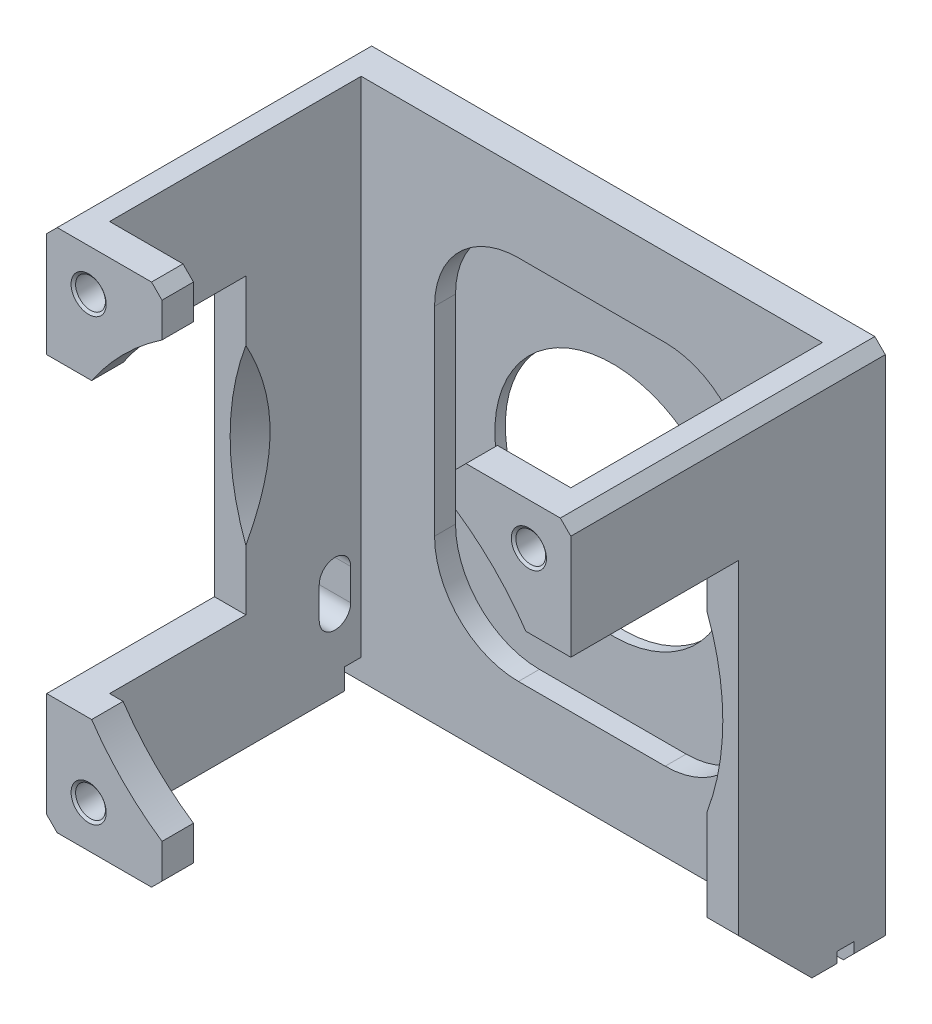
from build123d import *

# Parameters (mm, degrees)
SKETCH_1_W                   = 50
SKETCH_1_H                   = 30
SKETCH_1_W_2                 = 44
SKETCH_1_H_2                 = 24
EXTRUDE_1_DEPTH              = 50
CUT_EXTRUDE_START            = -14
CUT_EXTRUDE_1_DEPTH          = 17
SKETCH_3_R                   = 11.25
CUT_EXTRUDE_2_DEPTH          = 4
HOLE_WIZARD_4_40_D           = 2.8448
HOLE_WIZARD_4_40_DEPTH       = 3
HOLE_WIZARD_4_40_CSINK_D     = 3.3528
HOLE_WIZARD_4_40_CSINK_ANGLE = 110
SKETCH_10_W                  = 1.6
SKETCH_10_H                  = 2
CUT_EXTRUDE_4_DEPTH          = 51
CUT_EXTRUDE_3_DEPTH          = 2
CHAMFER_1_SIZE               = 8
CHAMFER_2_SIZE               = 1
CUT_EXTRUDE_5_REACH          = 52


with BuildPart() as part:
    # Эскиз1 → Бобышка-Вытянуть1 (new body)
    with BuildSketch(Plane(origin=(0, 0, 0), x_dir=(1, 0, 0), z_dir=(0, 1, 0))):
        Rectangle(SKETCH_1_W, SKETCH_1_H)
        Rectangle(SKETCH_1_W_2, SKETCH_1_H_2, mode=Mode.SUBTRACT)
    extrude(amount=EXTRUDE_1_DEPTH)

    # Эскиз2 → Вырез-Вытянуть1 (cut, through all)
    with BuildSketch(Plane(origin=(0, 0, -15), x_dir=(-1, 0, 0), z_dir=(0, 0, -1)).offset(CUT_EXTRUDE_START)):
        with BuildLine():
            ThreePointArc((-14, 45.712315177), (-17.67766953, 42.67766953), (-20.712315177, 39))
            Line((-20.712315177, 39), (-25, 39))
            Line((-25, 39), (-25, 11))
            Line((-25, 11), (-20.712315177, 11))
            ThreePointArc((-20.712315177, 11), (-17.67766953, 7.32233047), (-14, 4.287684823))
            Line((-14, 4.287684823), (-14, 0))
            Line((-14, 0), (14, 0))
            Line((14, 0), (14, 4.287684823))
            ThreePointArc((14, 4.287684823), (17.67766953, 7.32233047), (20.712315177, 11))
            Line((20.712315177, 11), (25, 11))
            Line((25, 11), (25, 39))
            Line((25, 39), (20.712315177, 39))
            ThreePointArc((20.712315177, 39), (17.67766953, 42.67766953), (14, 45.712315177))
            Line((14, 45.712315177), (14, 50))
            Line((14, 50), (-14, 50))
            Line((-14, 50), (-14, 45.712315177))
        make_face()
        with BuildLine():
            Line((-20.712315177, 11), (-25, 11))
            Line((-25, 11), (-25, 0))
            Line((-25, 0), (-14, 0))
            Line((-14, 0), (-14, 4.287684823))
            ThreePointArc((-14, 4.287684823), (-17.67766953, 7.32233047), (-20.712315177, 11))
        make_face()
    extrude(amount=-CUT_EXTRUDE_1_DEPTH, mode=Mode.SUBTRACT)

    # Эскиз3 → Вырез-Вытянуть2 (cut, through all)
    with BuildSketch(Plane.XY.offset(-12)):
        with Locations((0, 25)):
            Circle(SKETCH_3_R)
    extrude(amount=-CUT_EXTRUDE_2_DEPTH, mode=Mode.SUBTRACT)

    # Эскиз6 → Вырез-Повернуть1 (revolve, cut)
    with BuildSketch(Plane(origin=(0, 25, 0), x_dir=(-1, 0, 0), z_dir=(0, 1, 0))):
        Polygon((-22, -3.309797446), (-22, -1), (-23.5, -1), align=None)
    revolve(axis=Axis((0, 25, -15), (0, 0, 1)), mode=Mode.SUBTRACT)

    # Отверстие #4-40
    with Locations(Plane.XY.offset(15)):
        with Locations((-21, 46), (21, 46), (-21, 4)):
            CounterSinkHole(HOLE_WIZARD_4_40_D / 2, HOLE_WIZARD_4_40_CSINK_D / 2, depth=HOLE_WIZARD_4_40_DEPTH, counter_sink_angle=HOLE_WIZARD_4_40_CSINK_ANGLE)

    # Эскиз10 → Вырез-Вытянуть4 (cut, through all)
    with BuildSketch(Plane.ZY.offset(25)):
        with Locations((-11.2, 1)):
            Rectangle(SKETCH_10_W, SKETCH_10_H)
    extrude(amount=-CUT_EXTRUDE_4_DEPTH, mode=Mode.SUBTRACT)

    # Эскиз9 → Вырез-Вытянуть3 (cut)
    with BuildSketch(Plane.XY.offset(-12)):
        with BuildLine():
            Line((-7, 7.5), (7, 7.5))
            ThreePointArc((7, 7.5), (12.656854249, 9.843145751), (15, 15.5))
            Line((15, 15.5), (15, 34.5))
            ThreePointArc((15, 34.5), (12.656854249, 40.156854249), (7, 42.5))
            Line((7, 42.5), (-7, 42.5))
            ThreePointArc((-7, 42.5), (-12.656854249, 40.156854249), (-15, 34.5))
            Line((-15, 34.5), (-15, 15.5))
            ThreePointArc((-15, 15.5), (-12.656854249, 9.843145751), (-7, 7.5))
        make_face()
    extrude(amount=-CUT_EXTRUDE_3_DEPTH, mode=Mode.SUBTRACT)

    # Фаска1
    chamfer_1_edges = [part.edges().sort_by_distance(p)[0] for p in [
        (23.5, 0, -1),
    ]]
    chamfer(chamfer_1_edges, length=CHAMFER_1_SIZE)

    # Фаска2
    chamfer_2_edges = [part.edges().sort_by_distance(p)[0] for p in [
        (-25, 50, 0),
        (25, 0, -13.5),
        (-25, 0, 2.3),
        (25, 0, -9.7),
        (25, 50, 0),
        (-25, 0, -13.5),
        (14, 50, 13.5),
        (-14, 50, 13.5),
        (-14, 0, 13.5),
    ]]
    chamfer(chamfer_2_edges, length=CHAMFER_2_SIZE)

    # Эскиз11 → Вырез-Вытянуть5 (cut, up to next)
    with BuildSketch(Plane.ZY.offset(25), mode=Mode.PRIVATE) as cut_extrude_5_sk1:
        with BuildLine():
            Line((-8, 10), (-8, 7))
            ThreePointArc((-8, 7), (-9.5, 5.5), (-11, 7))
            Line((-11, 7), (-11, 10))
            ThreePointArc((-11, 10), (-9.5, 11.5), (-8, 10))
        make_face()
    cut_extrude_5_tool1 = extrude(cut_extrude_5_sk1.sketch, amount=-CUT_EXTRUDE_5_REACH, mode=Mode.PRIVATE) & part.part
    add(cut_extrude_5_tool1.solids().sort_by_distance((-25, 8.5, -9.5))[0], mode=Mode.SUBTRACT)


solid = part.part
